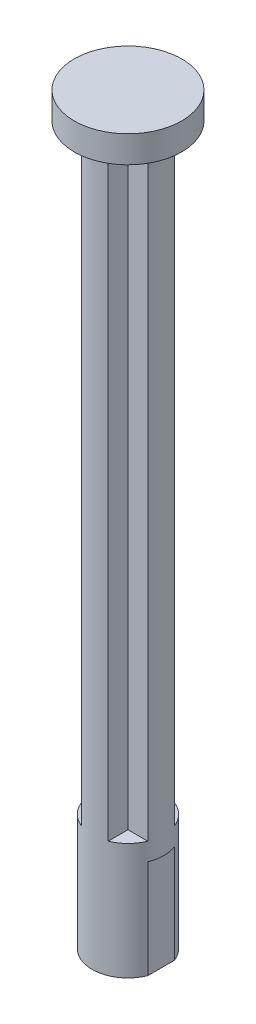
from build123d import *

# Parameters (mm, degrees)
SKETCH4_R               = 4
BOSS_EXTRUDE6_DEPTH     = 13
CUT_EXTRUDE3_DEPTH      = 1
CUT_EXTRUDE3_DEPTH_BACK = 11
SKETCH6_R               = 1.5
CUT_EXTRUDE4_DEPTH      = 3
BOSS_EXTRUDE7_DEPTH     = 67
SKETCH8_R               = 6
BOSS_EXTRUDE8_DEPTH     = 3


with BuildPart() as part:
    # Sketch4 → Boss-Extrude6 (new body)
    with BuildSketch(Plane(origin=(0, 0, 0), x_dir=(1, 0, 0), z_dir=(0, 1, 0))):
        Circle(SKETCH4_R)
    extrude(amount=BOSS_EXTRUDE6_DEPTH)

    # Sketch5 → Cut-Extrude3 (cut, two sides)
    with BuildSketch(Plane.XZ) as cut_extrude3_sk:
        with BuildLine():
            Line((-3.708099244, -1.5), (-3.708099244, 1.5))
            ThreePointArc((-3.708099244, 1.5), (-4, 0), (-3.708099244, -1.5))
        make_face()
        with BuildLine():
            Line((3.708099244, -1.5), (3.708099244, 1.5))
            ThreePointArc((3.708099244, 1.5), (4, 0), (3.708099244, -1.5))
        make_face()
    extrude(amount=CUT_EXTRUDE3_DEPTH, mode=Mode.SUBTRACT)
    extrude(cut_extrude3_sk.sketch, amount=-CUT_EXTRUDE3_DEPTH_BACK, mode=Mode.SUBTRACT)

    # Sketch6 → Cut-Extrude4 (cut)
    with BuildSketch(Plane.ZY.offset(3.708099244)):
        with Locations((0, 5)):
            Circle(SKETCH6_R)
    extrude(amount=-CUT_EXTRUDE4_DEPTH, mode=Mode.SUBTRACT)

    # Sketch7 → Boss-Extrude7 (add)
    with BuildSketch(Plane(origin=(0, 13, 0), x_dir=(1, 0, 0), z_dir=(0, 1, 0))):
        with BuildLine():
            Line((1.5, 1.5), (1.5, 3.708099244))
            ThreePointArc((1.5, 3.708099244), (0, 4), (-1.5, 3.708099244))
            Line((-1.5, 3.708099244), (-1.5, 1.5))
            Line((-1.5, 1.5), (-3.708099244, 1.5))
            ThreePointArc((-3.708099244, 1.5), (-4, 0), (-3.708099244, -1.5))
            Line((-3.708099244, -1.5), (-1.5, -1.5))
            Line((-1.5, -1.5), (-1.5, -3.708099244))
            ThreePointArc((-1.5, -3.708099244), (0, -4), (1.5, -3.708099244))
            Line((1.5, -3.708099244), (1.5, -1.5))
            Line((1.5, -1.5), (3.708099244, -1.5))
            ThreePointArc((3.708099244, -1.5), (4, 0), (3.708099244, 1.5))
            Line((3.708099244, 1.5), (1.5, 1.5))
        make_face()
    extrude(amount=BOSS_EXTRUDE7_DEPTH)

    # Sketch8 → Boss-Extrude8 (add)
    with BuildSketch(Plane(origin=(0, 80, 0), x_dir=(1, 0, 0), z_dir=(0, 1, 0))):
        Circle(SKETCH8_R)
    extrude(amount=BOSS_EXTRUDE8_DEPTH)


solid = part.part
